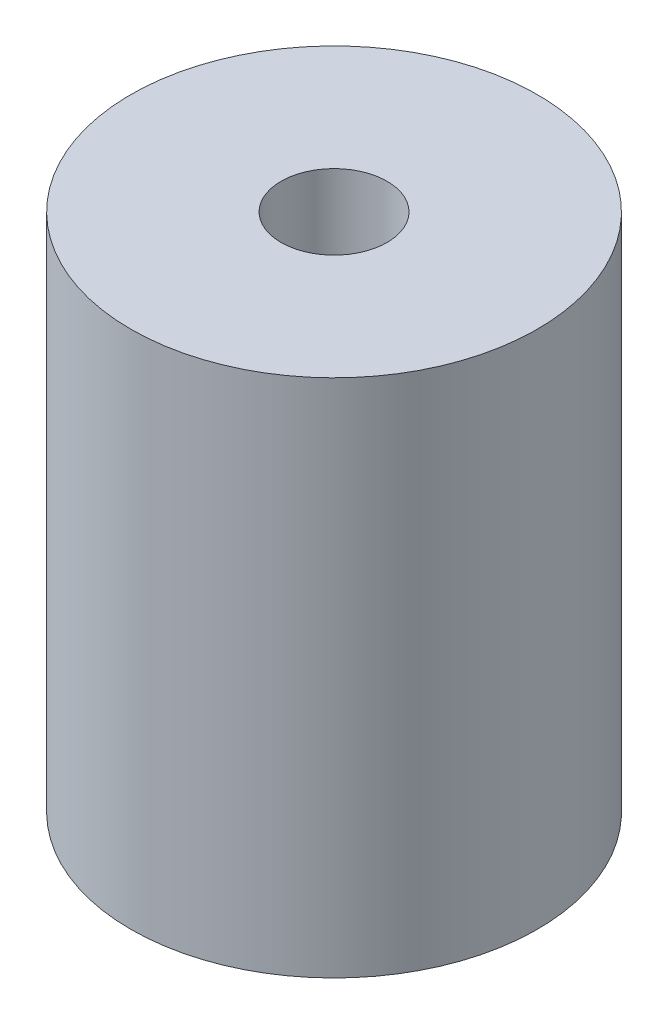
from build123d import *

# Parameters (mm, degrees)
SKETCH1_R           = 9.58
SKETCH1_R_2         = 4
BOSS_EXTRUDE1_DEPTH = 18
SKETCH2_R           = 9.58
SKETCH2_R_2         = 2.5
BOSS_EXTRUDE2_DEPTH = 6.5


with BuildPart() as part:
    # Sketch1 → Boss-Extrude1 (new body)
    with BuildSketch(Plane(origin=(0, 0, 0), x_dir=(1, 0, 0), z_dir=(0, 1, 0))):
        Circle(SKETCH1_R)
        Circle(SKETCH1_R_2, mode=Mode.SUBTRACT)
    extrude(amount=BOSS_EXTRUDE1_DEPTH)

    # Sketch2 → Boss-Extrude2 (add)
    with BuildSketch(Plane(origin=(0, 18, 0), x_dir=(1, 0, 0), z_dir=(0, 1, 0))):
        Circle(SKETCH2_R)
        Circle(SKETCH2_R_2, mode=Mode.SUBTRACT)
    extrude(amount=BOSS_EXTRUDE2_DEPTH)


solid = part.part
